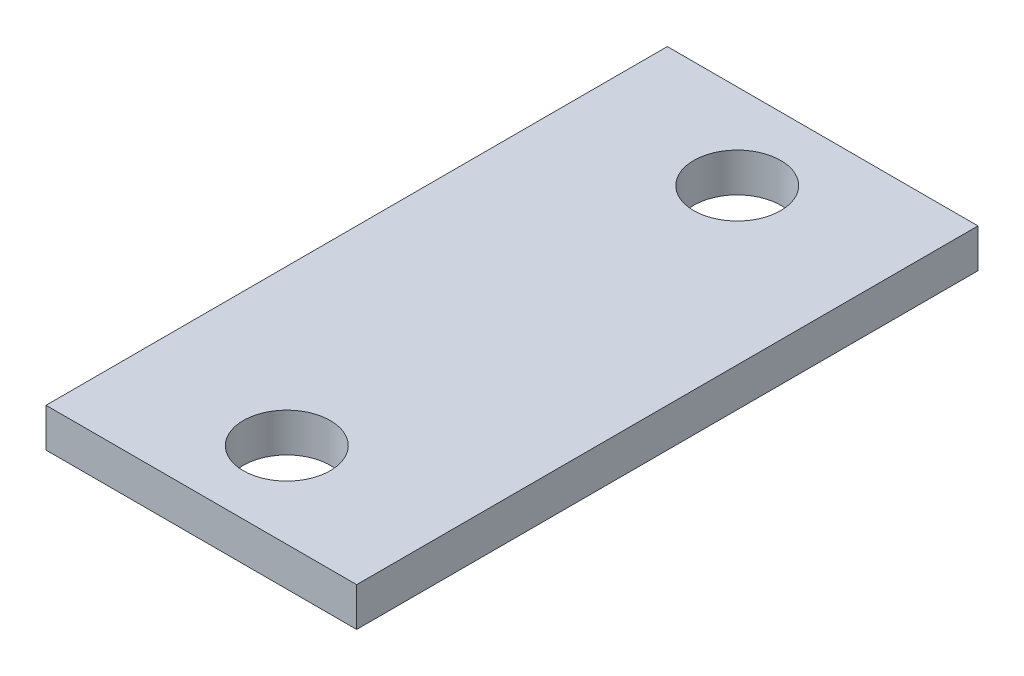
from build123d import *

# Parameters (mm, degrees)
SKETCH1_W    = 50.8
SKETCH1_H    = 101.6
SKETCH1_R    = 7.112
HAMMER_DEPTH = 6.35


with BuildPart() as part:
    # Sketch1 → Hammer (new body)
    with BuildSketch(Plane(origin=(0, 0, 0), x_dir=(1, 0, 0), z_dir=(0, 1, 0))):
        with Locations((25.4, 50.8)):
            Rectangle(SKETCH1_W, SKETCH1_H)
        with Locations((25.4, 13.97)):
            Circle(SKETCH1_R, mode=Mode.SUBTRACT)
        with Locations((25.4, 87.63)):
            Circle(SKETCH1_R, mode=Mode.SUBTRACT)
    extrude(amount=HAMMER_DEPTH)


solid = part.part
